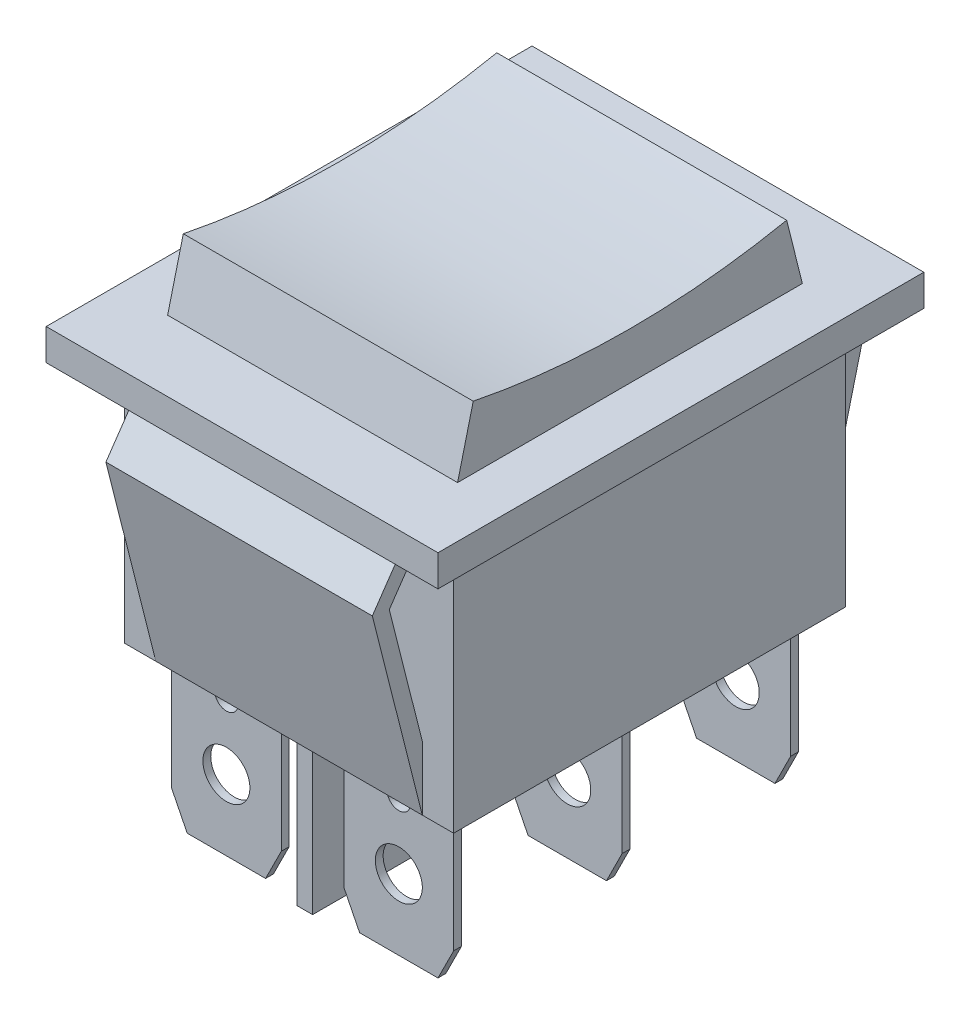
from build123d import *

# Parameters (mm, degrees)
SKETCH_1_W          = 25
SKETCH_1_H          = 31
EXTRUDE_1_DEPTH     = 2
SKETCH_2_W          = 21
SKETCH_2_H          = 25
EXTRUDE_2_DEPTH     = 16
EXTRUDE_3_DEPTH     = 9.25
EXTRUDE_5_DEPTH     = 8.5
SKETCH_5_W          = 1
SKETCH_5_H          = 23
SKETCH_5_W_2        = 9
SKETCH_5_H_2        = 0.5
EXTRUDE_6_DEPTH     = 10
SKETCH_6_R          = 1.5
SKETCH_6_R_2        = 0.75
CUT_EXTRUDE_1_DEPTH = 27.688922773


with BuildPart() as part:
    # Эскиз1 → Бобышка-Вытянуть1 (new body)
    with BuildSketch(Plane(origin=(0, 0, 0), x_dir=(1, 0, 0), z_dir=(0, 1, 0))):
        Rectangle(SKETCH_1_W, SKETCH_1_H)
    extrude(amount=EXTRUDE_1_DEPTH)

    # Эскиз2 → Бобышка-Вытянуть2 (add)
    with BuildSketch(Plane.XZ):
        Rectangle(SKETCH_2_W, SKETCH_2_H)
    extrude(amount=EXTRUDE_2_DEPTH)

    # Эскиз3 → Бобышка-Вытянуть3 (add, symmetric)
    with BuildSketch(Plane(origin=(0, 0, 0), x_dir=(0, 0, -1), z_dir=(1, 0, 0))):
        with BuildLine():
            Line((11, 2), (-11, 2))
            Line((-11, 2), (-10, 6))
            ThreePointArc((-10, 6), (0, 5), (10, 6))
            Line((10, 6), (11, 2))
        make_face()
    extrude(amount=EXTRUDE_3_DEPTH, both=True)

    # Эскиз4 → Бобышка-Вытянуть5 (add, symmetric)
    with BuildSketch(Plane(origin=(0, 0, 0), x_dir=(0, 0, -1), z_dir=(1, 0, 0))):
        Polygon((-12.5, -16), (-15.688922773, -3.397191918), (-13.42429798, -0.1), (-12.6, -0.666156198), (-14.608505885, -3.590450497), (-11.530553224, -15.754698248), align=None)
        Polygon((14.608505885, -3.590450497), (11.530553224, -15.754698248), (12.5, -16), (15.688922773, -3.397191918), (13.42429798, -0.1), (12.6, -0.666156198), align=None)
    extrude(amount=EXTRUDE_5_DEPTH, both=True)

    # Эскиз5 → Бобышка-Вытянуть6 (add)
    with BuildSketch(Plane.XZ.offset(16)):
        Rectangle(SKETCH_5_W, SKETCH_5_H)
        with Locations((5.5, -10.75)):
            Rectangle(SKETCH_5_W_2, SKETCH_5_H_2)
        with Locations((5.5, 10.75)):
            Rectangle(SKETCH_5_W_2, SKETCH_5_H_2)
        with Locations((5.5, 0)):
            Rectangle(SKETCH_5_W_2, SKETCH_5_H_2)
        with Locations((-5.5, -10.75)):
            Rectangle(SKETCH_5_W_2, SKETCH_5_H_2)
        with Locations((-5.5, 0)):
            Rectangle(SKETCH_5_W_2, SKETCH_5_H_2)
        with Locations((-5.5, 10.75)):
            Rectangle(SKETCH_5_W_2, SKETCH_5_H_2)
    extrude(amount=EXTRUDE_6_DEPTH)

    # Эскиз6 → Вырез-Вытянуть1 (cut, through all)
    with BuildSketch(Plane(origin=(0, 0, -11), x_dir=(-1, 0, 0), z_dir=(0, 0, -1))):
        with Locations((-5.5, -21.5)):
            Circle(SKETCH_6_R)
        with Locations((-5.5, -17.25)):
            Circle(SKETCH_6_R_2)
        with Locations((5.5, -17.25)):
            Circle(SKETCH_6_R_2)
        with Locations((5.5, -21.5)):
            Circle(SKETCH_6_R)
        Polygon((-10.25, -16.5), (-9, -16.5), (-9, -24), (-8, -26), (-8, -27.807511946), (-10.25, -27.807511946), align=None)
        Polygon((-3, -27.807511946), (-0.75, -27.807511946), (-0.75, -16.5), (-2, -16.5), (-2, -24), (-3, -26), align=None)
        Polygon((3, -26), (3, -27.807511946), (0.75, -27.807511946), (0.75, -16.5), (2, -16.5), (2, -24), align=None)
        Polygon((8, -27.807511946), (10.25, -27.807511946), (10.25, -16.5), (9, -16.5), (9, -24), (8, -26), align=None)
    extrude(amount=-CUT_EXTRUDE_1_DEPTH, mode=Mode.SUBTRACT)


solid = part.part
